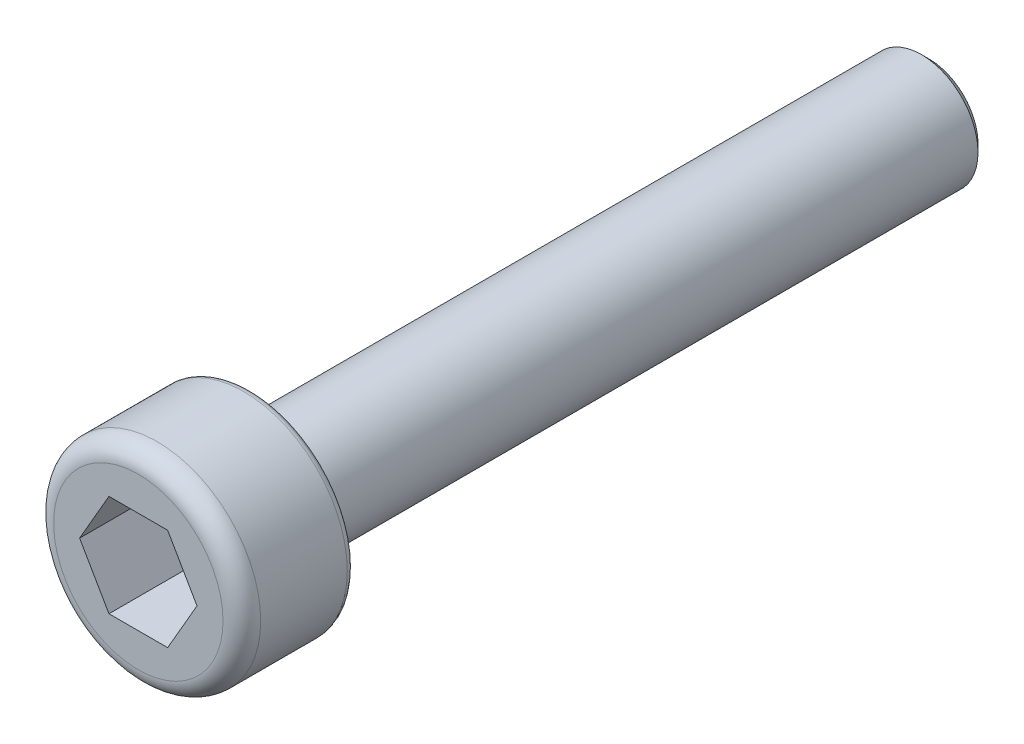
from build123d import *

# Parameters (mm, degrees)
SKETCH_1_R          = 2.75
EXTRUDE_1_DEPTH     = 3
FILLET_1_R          = 0.5
CUT_EXTRUDE_1_DEPTH = 2
SKETCH_3_R          = 1.5
EXTRUDE_2_DEPTH     = 18
CHAMFER_1_SIZE      = 0.2
FILLET_2_R          = 0.2


with BuildPart() as part:
    # 草图1 → 凸台-拉伸1 (new body)
    with BuildSketch(Plane.XY):
        Circle(SKETCH_1_R)
    extrude(amount=EXTRUDE_1_DEPTH)

    # 圆角1
    fillet_1_edges = [part.edges().sort_by_distance(p)[0] for p in [
        (-2.75, 0, 3),
    ]]
    fillet(fillet_1_edges, radius=FILLET_1_R)

    # 草图2 → 切除-拉伸1 (cut)
    with BuildSketch(Plane.XY.offset(3)):
        Polygon((1.558845727, 0), (0.779422863, 1.35), (-0.779422863, 1.35), (-1.558845727, 0), (-0.779422863, -1.35), (0.779422863, -1.35), align=None)
    extrude(amount=-CUT_EXTRUDE_1_DEPTH, mode=Mode.SUBTRACT)

    # 草图3 → 凸台-拉伸2 (add)
    with BuildSketch(Plane(origin=(0, 0, 0), x_dir=(-1, 0, 0), z_dir=(0, 0, -1))):
        Circle(SKETCH_3_R)
    extrude(amount=EXTRUDE_2_DEPTH)

    # 倒角1
    chamfer_1_edges = [part.edges().sort_by_distance(p)[0] for p in [
        (1.5, 0, -18),
    ]]
    chamfer(chamfer_1_edges, length=CHAMFER_1_SIZE)

    # 圆角2
    fillet_2_edges = [part.edges().sort_by_distance(p)[0] for p in [
        (-2.75, 0, 0),
    ]]
    fillet(fillet_2_edges, radius=FILLET_2_R)


solid = part.part
